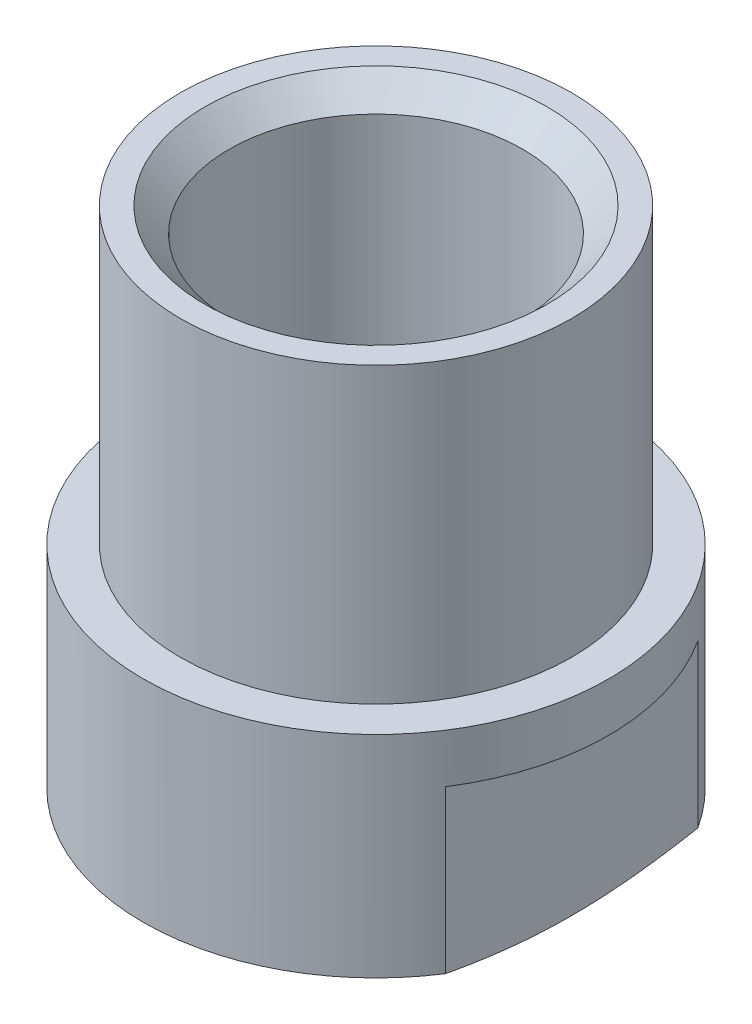
from build123d import *

# Parameters (mm, degrees)
CHAFL_N1_SIZE         = 2
CHAFL_N1_SIZE2        = 0.688655227
CHAFL_N2_SIZE         = 0.5
CROQUIS2_OUTSIDE_W    = 14.998
CROQUIS2_OUTSIDE_H    = 14.998
CROQUIS2_OUTSIDE_W_2  = 8
CROQUIS2_OUTSIDE_H_2  = 12
CORTAR_EXTRUIR1_DEPTH = 4


with BuildPart() as part:
    # Croquis1 → Revolución2 (revolve)
    with BuildSketch(Plane.XY):
        Polygon((2.3, 0), (4.76, 0), (4.76, 5), (4, 5), (4, 11), (3, 11), (3, 1), (1.5, 1), (1.5, 0.8), align=None)
    revolve(axis=Axis((0, 26.23655914, 0), (0, -1, 0)))

    # Chaflán1
    chafl_n1_edges = [part.edges().sort_by_distance(p)[0] for p in [
        (-4.76, 0, 0),
    ]]
    chafl_n1_side = [part.faces().sort_by_distance(p)[0] for p in [
        (-2.434633131, 0, 0),
    ]]
    chamfer(chafl_n1_edges, length=CHAFL_N1_SIZE, length2=CHAFL_N1_SIZE2, reference=chafl_n1_side[0])

    # Chaflán2
    chafl_n2_edges = [part.edges().sort_by_distance(p)[0] for p in [
        (-3, 11, 0),
    ]]
    chamfer(chafl_n2_edges, length=CHAFL_N2_SIZE)

    # Croquis2 outside → Cortar-Extruir1 (cut)
    with BuildSketch(Plane.XZ):
        Rectangle(CROQUIS2_OUTSIDE_W, CROQUIS2_OUTSIDE_H)
        Rectangle(CROQUIS2_OUTSIDE_W_2, CROQUIS2_OUTSIDE_H_2, mode=Mode.SUBTRACT)
    extrude(amount=-CORTAR_EXTRUIR1_DEPTH, mode=Mode.SUBTRACT)


solid = part.part
